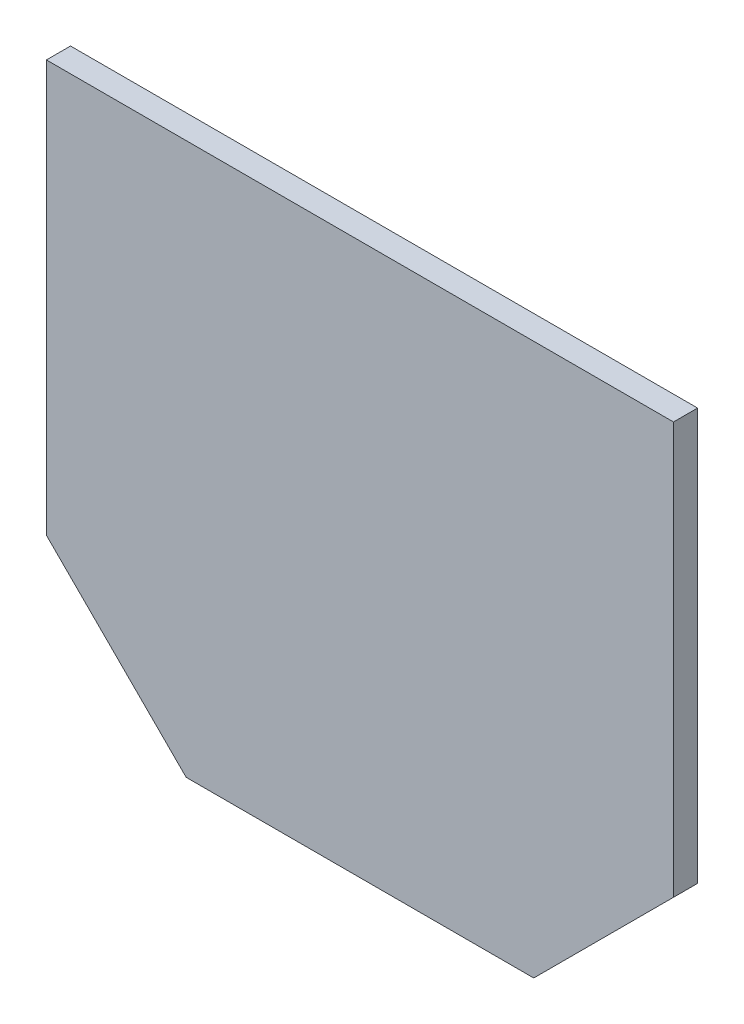
from build123d import *

# Parameters (mm, degrees)
BOSS_EXTRUDE1_DEPTH = 12.7


with BuildPart() as part:
    # Sketch2 → Boss-Extrude1 (new body)
    with BuildSketch(Plane.XY):
        Polygon((0, 0), (183.134, 0), (256.772100193, 73.638100193), (256.772100193, 290.554100193), (-73.638100193, 290.554100193), (-73.638100193, 73.638100193), align=None)
    extrude(amount=BOSS_EXTRUDE1_DEPTH)


solid = part.part
